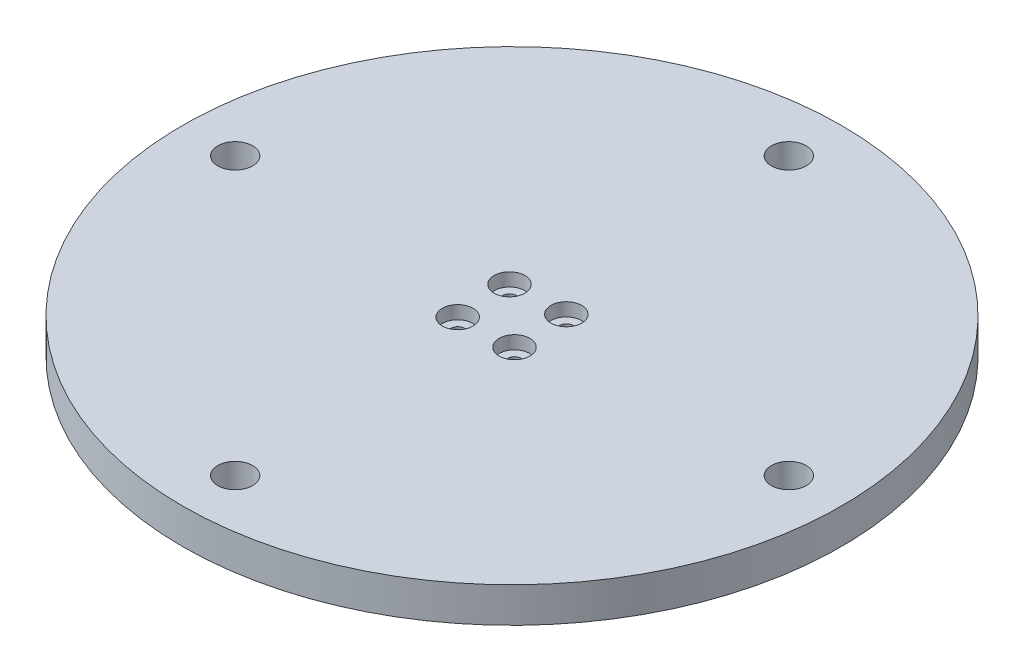
from build123d import *

# Parameters (mm, degrees)
CROQUIS1_R              = 15
CROQUIS1_R_2            = 13
EXTRUIR_L_MINA1_DEPTH   = 18
CROQUIS2_R              = 75
SALIENTE_EXTRUIR1_DEPTH = 8
CROQUIS3_R              = 1.59
CROQUIS3_R_2            = 1.5875
CORTAR_EXTRUIR1_DEPTH   = 10
CROQUIS5_R              = 3.969
CORTAR_EXTRUIR2_DEPTH   = 10
CROQUIS6_R              = 3.5
CORTAR_EXTRUIR3_DEPTH   = 3


with BuildPart() as part:
    # Croquis1 → Extruir-Lámina1 (new body)
    with BuildSketch(Plane(origin=(0, 0, 0), x_dir=(1, 0, 0), z_dir=(0, 1, 0))):
        Circle(CROQUIS1_R)
        Circle(CROQUIS1_R_2, mode=Mode.SUBTRACT)
    extrude(amount=EXTRUIR_L_MINA1_DEPTH)

    # Croquis2 → Saliente-Extruir1 (add)
    with BuildSketch(Plane(origin=(0, 18, 0), x_dir=(1, 0, 0), z_dir=(0, 1, 0))):
        Circle(CROQUIS2_R)
    extrude(amount=SALIENTE_EXTRUIR1_DEPTH)

    # Croquis3 → Cortar-Extruir1 (cut)
    with BuildSketch(Plane(origin=(0, 26, 0), x_dir=(1, 0, 0), z_dir=(0, 1, 0))):
        with Locations((5.896947673, 6.464403154)):
            Circle(CROQUIS3_R)
        with Locations((-5.896947673, -6.464403154)):
            Circle(CROQUIS3_R)
        with Locations((6.492053366, -5.922170706)):
            Circle(CROQUIS3_R)
        with Locations((-6.464403154, 5.896947673)):
            Circle(CROQUIS3_R_2)
    extrude(amount=-CORTAR_EXTRUIR1_DEPTH, mode=Mode.SUBTRACT)

    # Croquis5 → Cortar-Extruir2 (cut)
    with BuildSketch(Plane.XZ.offset(-18)):
        with Locations((0, -63)):
            Circle(CROQUIS5_R)
        with Locations((-63, 0)):
            Circle(CROQUIS5_R)
        with Locations((0, 63)):
            Circle(CROQUIS5_R)
        with Locations((63, 0)):
            Circle(CROQUIS5_R)
    extrude(amount=-CORTAR_EXTRUIR2_DEPTH, mode=Mode.SUBTRACT)

    # Croquis6 → Cortar-Extruir3 (cut)
    with BuildSketch(Plane(origin=(0, 26, 0), x_dir=(1, 0, 0), z_dir=(0, 1, 0))):
        with Locations((5.896947673, 6.464403154)):
            Circle(CROQUIS6_R)
        with Locations((-6.464403154, 5.896947673)):
            Circle(CROQUIS6_R)
        with Locations((-5.896947673, -6.464403154)):
            Circle(CROQUIS6_R)
        with Locations((6.492053366, -5.922170706)):
            Circle(CROQUIS6_R)
    extrude(amount=-CORTAR_EXTRUIR3_DEPTH, mode=Mode.SUBTRACT)


solid = part.part
